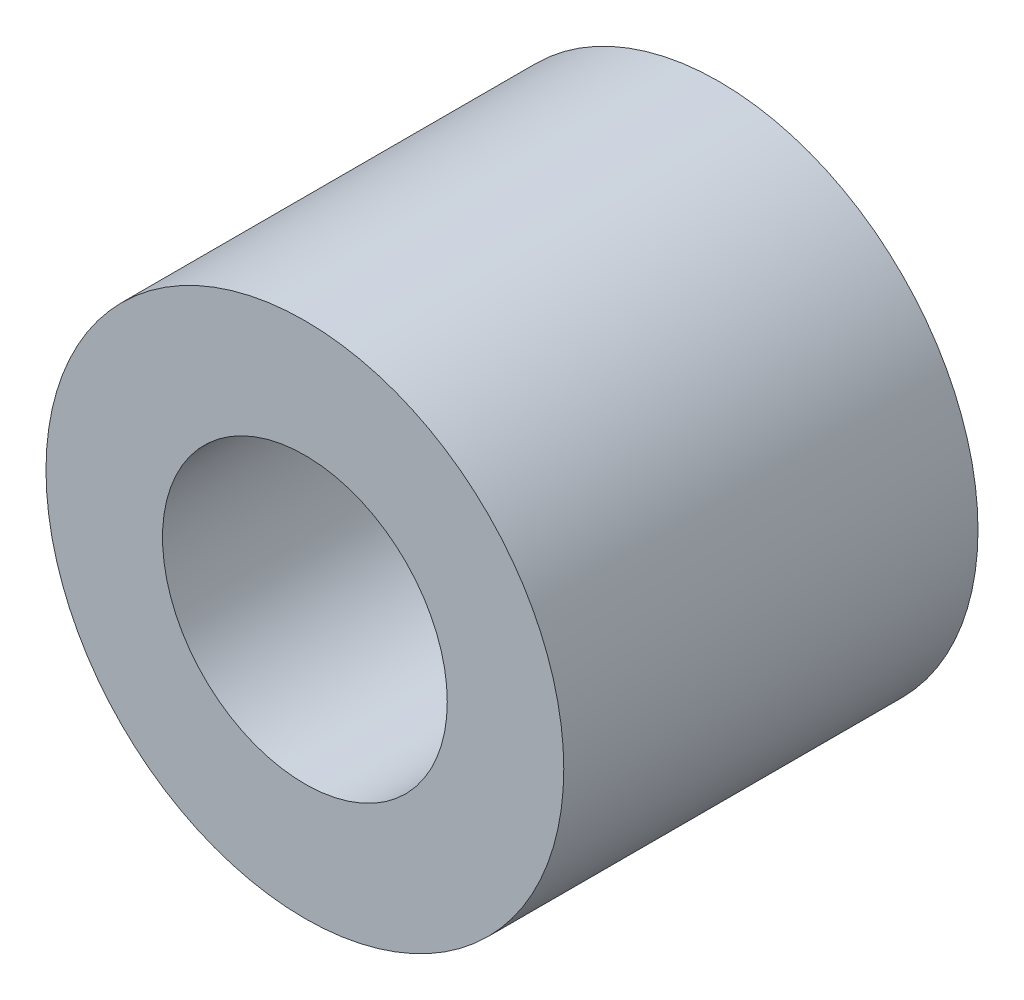
from build123d import *

# Parameters (mm, degrees)
SKETCH1_R           = 2.5
SKETCH1_R_2         = 1.375
BOSS_EXTRUDE2_DEPTH = 4


with BuildPart() as part:
    # Sketch1 → Boss-Extrude2 (new body)
    with BuildSketch(Plane.XY):
        Circle(SKETCH1_R)
        Circle(SKETCH1_R_2, mode=Mode.SUBTRACT)
    extrude(amount=BOSS_EXTRUDE2_DEPTH)


solid = part.part
